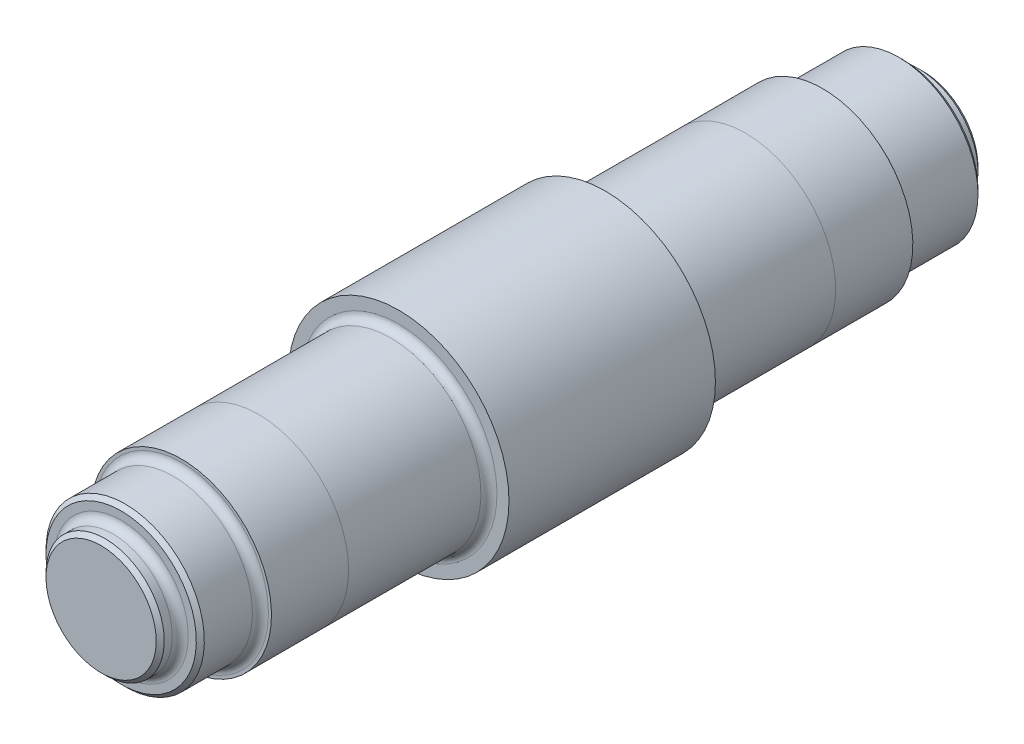
from build123d import *

# Parameters (mm, degrees)
BEARINGBOREFILLET_R = 0.4
FILLET2_R           = 0.4
CUT_EXTRUDE1_START  = 20
SKETCH2_OUTSIDE_W   = 21.77
SKETCH2_OUTSIDE_H   = 21.77
SKETCH2_OUTSIDE_R   = 2.95
CUT_EXTRUDE1_DEPTH  = 1
CUT_EXTRUDE2_START  = -21
SKETCH2_2_OUTSIDE_W = 21.77
SKETCH2_2_OUTSIDE_H = 21.77
SKETCH2_2_OUTSIDE_R = 2.95
CUT_EXTRUDE2_DEPTH  = 1
FILLET3_R           = 0.4
CHAMFER1_SIZE       = 0.2


with BuildPart() as part:
    # Sketch1 → Revolve1 (revolve)
    with BuildSketch(Plane(origin=(0, 0, 0), x_dir=(0, 0, -1), z_dir=(1, 0, 0))):
        Polygon((5.15, 5.5), (5.15, 4.5), (15, 4.5), (16, 4.5), (16, 3.95), (21, 3.95), (21, 0), (-20, 0), (-20, 3.95), (-16, 3.95), (-16, 4.5), (-15, 4.5), (-5.15, 4.5), (-5.15, 5.5), align=None)
    revolve(axis=Axis((0, 0, 20), (0, 0, -1)))

    # bearingBoreFillet
    bearingborefillet_edges = [part.edges().sort_by_distance(p)[0] for p in [
        (0, -4.5, -5.15),
        (0, -4.5, 5.15),
    ]]
    fillet(bearingborefillet_edges, radius=BEARINGBOREFILLET_R)

    # Fillet2
    fillet2_edges = [part.edges().sort_by_distance(p)[0] for p in [
        (0, -3.95, 16),
        (0, -3.95, -16),
    ]]
    fillet(fillet2_edges, radius=FILLET2_R)

    # Sketch2 outside → Cut-Extrude1 (cut)
    with BuildSketch(Plane.XY.offset(CUT_EXTRUDE1_START)):
        Rectangle(SKETCH2_OUTSIDE_W, SKETCH2_OUTSIDE_H)
        Circle(SKETCH2_OUTSIDE_R, mode=Mode.SUBTRACT)
    extrude(amount=-CUT_EXTRUDE1_DEPTH, mode=Mode.SUBTRACT)

    # Sketch2_2 outside → Cut-Extrude2 (cut)
    with BuildSketch(Plane.XY.offset(CUT_EXTRUDE2_START)):
        Rectangle(SKETCH2_2_OUTSIDE_W, SKETCH2_2_OUTSIDE_H)
        Circle(SKETCH2_2_OUTSIDE_R, mode=Mode.SUBTRACT)
    extrude(amount=CUT_EXTRUDE2_DEPTH, mode=Mode.SUBTRACT)

    # Fillet3
    fillet3_edges = [part.edges().sort_by_distance(p)[0] for p in [
        (-2.95, 0, 19),
        (-2.95, 0, -20),
    ]]
    fillet(fillet3_edges, radius=FILLET3_R)

    # Chamfer1
    chamfer1_edges = [part.edges().sort_by_distance(p)[0] for p in [
        (0, -3.95, 19),
        (-2.95, 0, 20),
        (-2.95, 0, -21),
        (0, -3.95, -20),
    ]]
    chamfer(chamfer1_edges, length=CHAMFER1_SIZE)


solid = part.part
